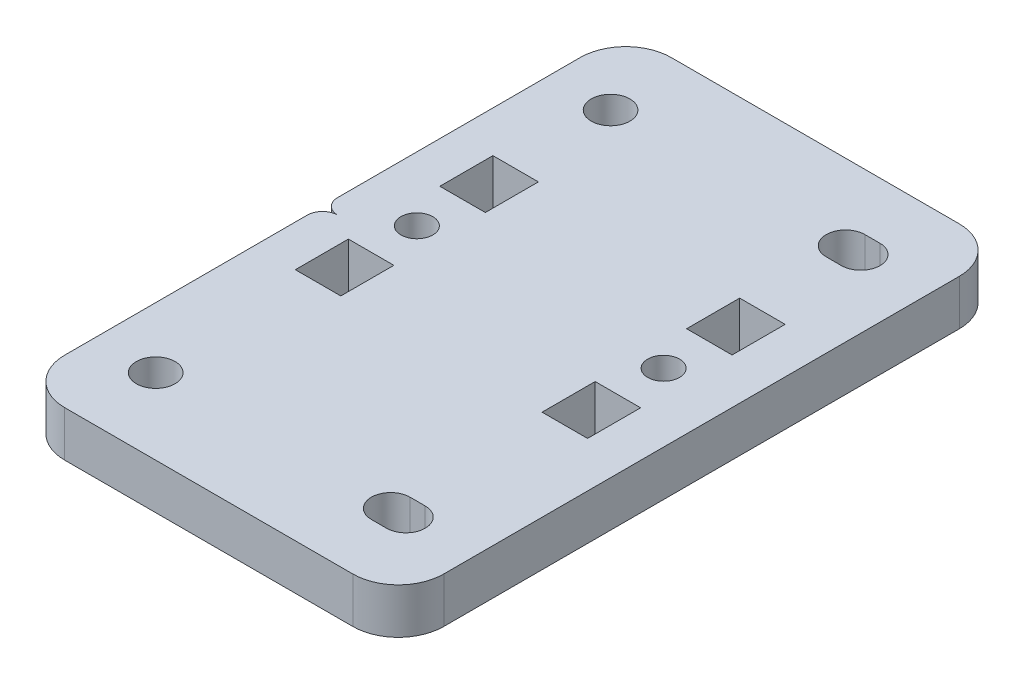
from build123d import *

# Parameters (mm, degrees)
EXTRUDE_1_DEPTH      = 6
SKETCH_2_R           = 2.55
CUT_EXTRUDE_1_DEPTH  = 7
CUT_EXTRUDE_2_DEPTH  = 7
SKETCH_31_R          = 2.1
SKETCH_31_W          = 7
SKETCH_31_H          = 6
CUT_EXTRUDE_11_DEPTH = 7
SKETCH_32_R          = 2.1
SKETCH_32_W          = 7
SKETCH_32_H          = 6
CUT_EXTRUDE_12_DEPTH = 7


with BuildPart() as part:
    # Эскиз1 → Бобышка-Вытянуть1 (new body)
    with BuildSketch(Plane(origin=(0, 0, 0), x_dir=(1, 0, 0), z_dir=(0, 1, 0))):
        with BuildLine():
            Line((-19, -40), (19, -40))
            ThreePointArc((19, -40), (23.242640687, -38.242640687), (25, -34))
            Line((25, -34), (25, 34))
            ThreePointArc((25, 34), (23.242640687, 38.242640687), (19, 40))
            Line((19, 40), (-19, 40))
            ThreePointArc((-19, 40), (-23.242640687, 38.242640687), (-25, 34))
            Line((-25, 34), (-25, -34))
            ThreePointArc((-25, -34), (-23.242640687, -38.242640687), (-19, -40))
        make_face()
    extrude(amount=EXTRUDE_1_DEPTH)

    # Эскиз2 → Вырез-Вытянуть1 (cut, through all)
    with BuildSketch(Plane.XZ):
        with Locations((-17, -30)):
            Circle(SKETCH_2_R)
        with Locations((-17, 30)):
            Circle(SKETCH_2_R)
        with BuildLine():
            Line((16, -32.55), (14, -32.55))
            ThreePointArc((14, -32.55), (11.45, -30), (14, -27.45))
            Line((14, -27.45), (16, -27.45))
            ThreePointArc((16, -27.45), (18.55, -30), (16, -32.55))
        make_face()
        with BuildLine():
            Line((16, 32.55), (14, 32.55))
            ThreePointArc((14, 32.55), (11.45, 30), (14, 27.45))
            Line((14, 27.45), (16, 27.45))
            ThreePointArc((16, 27.45), (18.55, 30), (16, 32.55))
        make_face()
    extrude(amount=-CUT_EXTRUDE_1_DEPTH, mode=Mode.SUBTRACT)

    # Эскиз3 → Вырез-Вытянуть2 (cut, through all)
    with BuildSketch(Plane.XZ):
        with BuildLine():
            Line((-25, -2), (-25, 2))
            ThreePointArc((-25, 2), (-24.414213562, 0.585786438), (-23, 0))
            ThreePointArc((-23, 0), (-24.414213562, -0.585786438), (-25, -2))
        make_face()
    extrude(amount=-CUT_EXTRUDE_2_DEPTH, mode=Mode.SUBTRACT)

    # Эскиз31 → Вырез-Вытянуть11 (cut, through all)
    with BuildSketch(Plane(origin=(30.45, 0, -4), x_dir=(0, 0, 1), z_dir=(0, -1, 0))):
        with Locations((0, 47)):
            Circle(SKETCH_31_R)
        with Locations((9.531849908, 47)):
            Rectangle(SKETCH_31_W, SKETCH_31_H)
        with Locations((-9.531849908, 47)):
            Rectangle(SKETCH_31_W, SKETCH_31_H)
    extrude(amount=-CUT_EXTRUDE_11_DEPTH, mode=Mode.SUBTRACT)

    # Эскиз32 → Вырез-Вытянуть12 (cut, through all)
    with BuildSketch(Plane(origin=(-31, 0, -4), x_dir=(0, 0, -1), z_dir=(0, -1, 0))):
        with Locations((0, 47)):
            Circle(SKETCH_32_R)
        with Locations((9.531849908, 47)):
            Rectangle(SKETCH_32_W, SKETCH_32_H)
        with Locations((-9.531849908, 47)):
            Rectangle(SKETCH_32_W, SKETCH_32_H)
    extrude(amount=-CUT_EXTRUDE_12_DEPTH, mode=Mode.SUBTRACT)


solid = part.part
